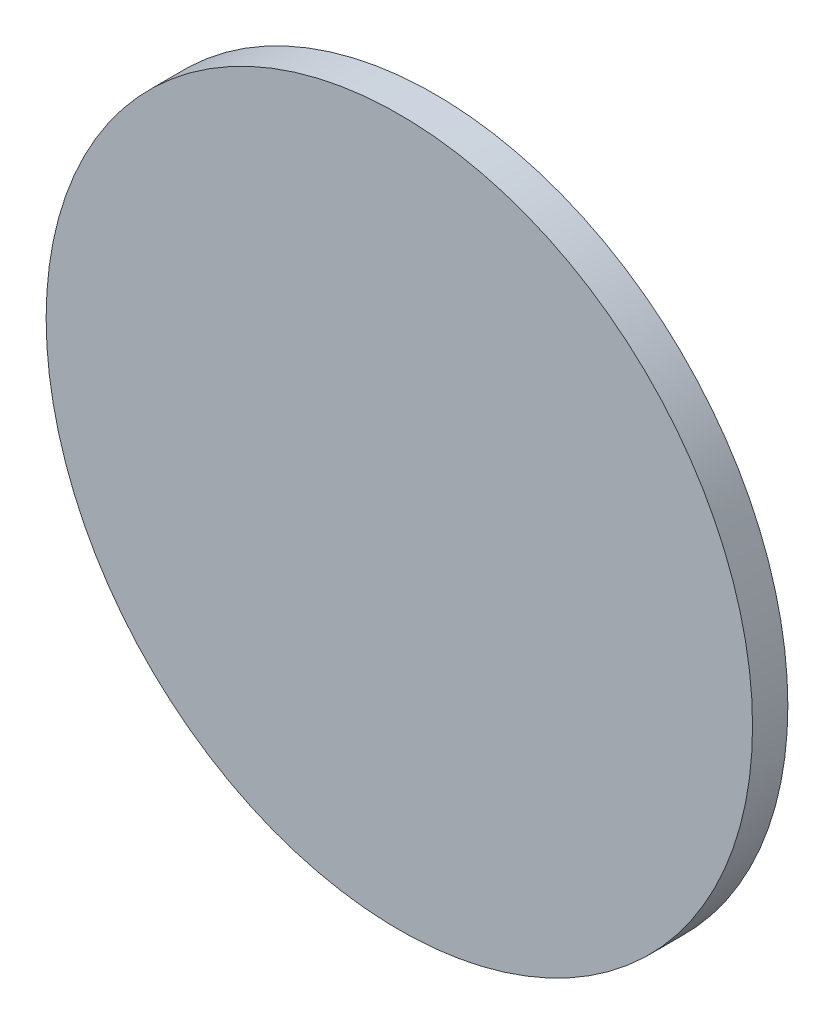
from build123d import *

# Parameters (mm, degrees)
SKETCH_1_R      = 20
EXTRUDE_1_DEPTH = 2


with BuildPart() as part:
    # 草图1 → 凸台-拉伸1 (new body)
    with BuildSketch(Plane.XY):
        Circle(SKETCH_1_R)
    extrude(amount=EXTRUDE_1_DEPTH)


solid = part.part
